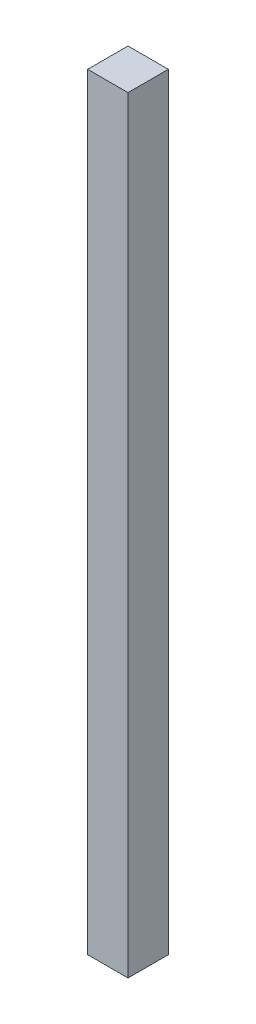
from build123d import *

# Parameters (mm, degrees)
SKETCH1_W           = 10
SKETCH1_H           = 10
BOSS_EXTRUDE1_DEPTH = 190


with BuildPart() as part:
    # Sketch1 → Boss-Extrude1 (new body)
    with BuildSketch(Plane(origin=(0, 0, 0), x_dir=(1, 0, 0), z_dir=(0, 1, 0))):
        with Locations((5, 5)):
            Rectangle(SKETCH1_W, SKETCH1_H)
    extrude(amount=BOSS_EXTRUDE1_DEPTH)


solid = part.part
